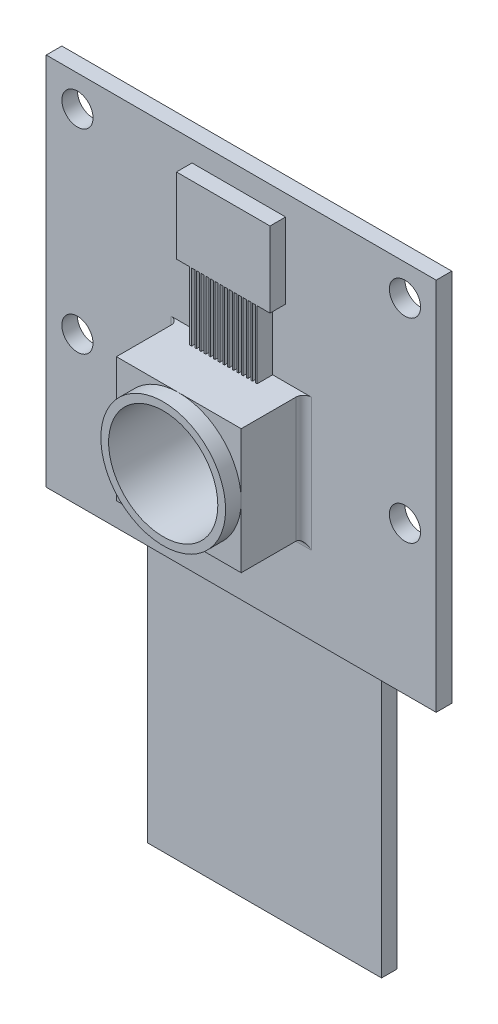
from build123d import *

# Parameters (mm, degrees)
SKETCH1_W           = 25
SKETCH1_H           = 24
SKETCH1_R           = 1
BOSS_EXTRUDE1_DEPTH = 1
SKETCH2_W           = 8
SKETCH2_H           = 8
BOSS_EXTRUDE2_DEPTH = 4
SKETCH3_R           = 4
BOSS_EXTRUDE3_DEPTH = 1
FILLET2_R           = 0.5
SKETCH4_W           = 16
SKETCH4_H           = 5
BOSS_EXTRUDE4_DEPTH = 2
FILLET3_R           = 0.5
SKETCH5_R           = 3.5
CUT_EXTRUDE1_DEPTH  = 6
BOSS_EXTRUDE5_DEPTH = 1
SKETCH7_W           = 0.2
SKETCH7_H           = 4.34
CUT_EXTRUDE2_DEPTH  = 1
LPATTERN1_COUNT     = 14
LPATTERN1_PITCH     = 0.3
SKETCH8_W           = 15
SKETCH8_H           = 1
BOSS_EXTRUDE6_DEPTH = 20


with BuildPart() as part:
    # Sketch1 → Boss-Extrude1 (new body)
    with BuildSketch(Plane.XY):
        Rectangle(SKETCH1_W, SKETCH1_H)
        with Locations((10.5, 10)):
            Circle(SKETCH1_R, mode=Mode.SUBTRACT)
        with Locations((-10.5, 10)):
            Circle(SKETCH1_R, mode=Mode.SUBTRACT)
        with Locations((-10.5, -2.5)):
            Circle(SKETCH1_R, mode=Mode.SUBTRACT)
        with Locations((10.5, -2.5)):
            Circle(SKETCH1_R, mode=Mode.SUBTRACT)
    extrude(amount=BOSS_EXTRUDE1_DEPTH)

    # Sketch2 → Boss-Extrude2 (add)
    with BuildSketch(Plane.XY.offset(1)):
        with Locations((0, -2.5)):
            Rectangle(SKETCH2_W, SKETCH2_H)
    extrude(amount=BOSS_EXTRUDE2_DEPTH)

    # Sketch3 → Boss-Extrude3 (add)
    with BuildSketch(Plane.XY.offset(5)):
        with Locations((0, -2.5)):
            Circle(SKETCH3_R)
    extrude(amount=BOSS_EXTRUDE3_DEPTH)

    # Fillet2
    fillet2_edges = [part.edges().sort_by_distance(p)[0] for p in [
        (4, -2.5, 1),
        (-4, -2.5, 1),
        (0, -6.5, 1),
    ]]
    fillet(fillet2_edges, radius=FILLET2_R)

    # Sketch4 → Boss-Extrude4 (add)
    with BuildSketch(Plane(origin=(0, 0, 0), x_dir=(-1, 0, 0), z_dir=(0, 0, -1))):
        with Locations((0, -7.5)):
            Rectangle(SKETCH4_W, SKETCH4_H)
    extrude(amount=BOSS_EXTRUDE4_DEPTH)

    # Fillet3
    fillet3_edges = [part.edges().sort_by_distance(p)[0] for p in [
        (-8, -7.5, 0),
        (-8, -10, -1),
        (0, -5, 0),
        (-8, -5, -1),
        (8, -7.5, 0),
        (8, -5, -1),
        (0, -10, 0),
        (8, -10, -1),
        (-8, -7.5, -2),
        (0, -5, -2),
        (8, -7.5, -2),
        (0, -10, -2),
    ]]
    fillet(fillet3_edges, radius=FILLET3_R)

    # Sketch5 → Cut-Extrude1 (cut)
    with BuildSketch(Plane.XY.offset(6)):
        with Locations((0, -2.5)):
            Circle(SKETCH5_R)
    extrude(amount=-CUT_EXTRUDE1_DEPTH, mode=Mode.SUBTRACT)

    # Sketch6 → Boss-Extrude5 (add)
    with BuildSketch(Plane.XY.offset(1)):
        Polygon((-3.152517362, 10.68), (-3.152517362, 5.84), (-2.322578899, 5.84), (-2.322578899, 1.5), (2.017421101, 1.5), (2.017421101, 5.84), (2.846354447, 5.84), (2.846354447, 6.468877905), (2.846354447, 10.68), align=None)
    extrude(amount=BOSS_EXTRUDE5_DEPTH)

    # Sketch7 → Cut-Extrude2 (cut)
    with BuildSketch(Plane.XY.offset(2)):
        with Locations((-2.072578899, 3.67)):
            Rectangle(SKETCH7_W, SKETCH7_H)
    cut_extrude2 = extrude(amount=-CUT_EXTRUDE2_DEPTH, mode=Mode.SUBTRACT)

    # LPattern1: Cut-Extrude2 ×14
    with Locations(*[(i * LPATTERN1_PITCH, 0, 0) for i in range(1, LPATTERN1_COUNT)]):
        add(cut_extrude2, mode=Mode.SUBTRACT)

    # Sketch8 → Boss-Extrude6 (add)
    with BuildSketch(Plane.XZ.offset(10)):
        with Locations((0, -1)):
            Rectangle(SKETCH8_W, SKETCH8_H)
    extrude(amount=BOSS_EXTRUDE6_DEPTH)


solid = part.part
